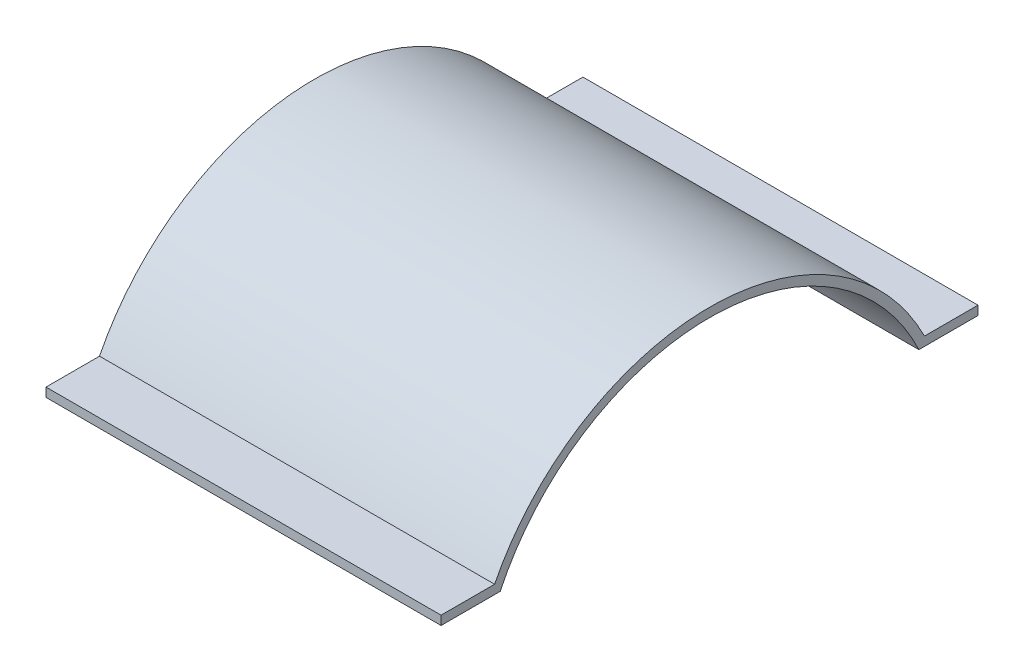
from build123d import *

# Parameters (mm, degrees)
BOSS_EXTRUDE1_DEPTH = 44


with BuildPart() as part:
    # Sketch1 → Boss-Extrude1 (new body)
    with BuildSketch(Plane(origin=(0, 0, 0), x_dir=(0, 0, -1), z_dir=(1, 0, 0))):
        with BuildLine():
            ThreePointArc((-24.093171188, 0), (-0.779280479, 14.75), (22.534610231, 0))
            Line((22.534610231, 0), (29.120719521, 0))
            Line((29.120719521, 0), (29.120719521, 1))
            Line((29.120719521, 1), (23.158921208, 1))
            ThreePointArc((23.158921208, 1), (-0.779280479, 15.75), (-24.717482165, 1))
            Line((-24.717482165, 1), (-30.679280479, 1))
            Line((-30.679280479, 1), (-30.679280479, 0))
            Line((-30.679280479, 0), (-24.093171188, 0))
        make_face()
    extrude(amount=BOSS_EXTRUDE1_DEPTH)


solid = part.part
